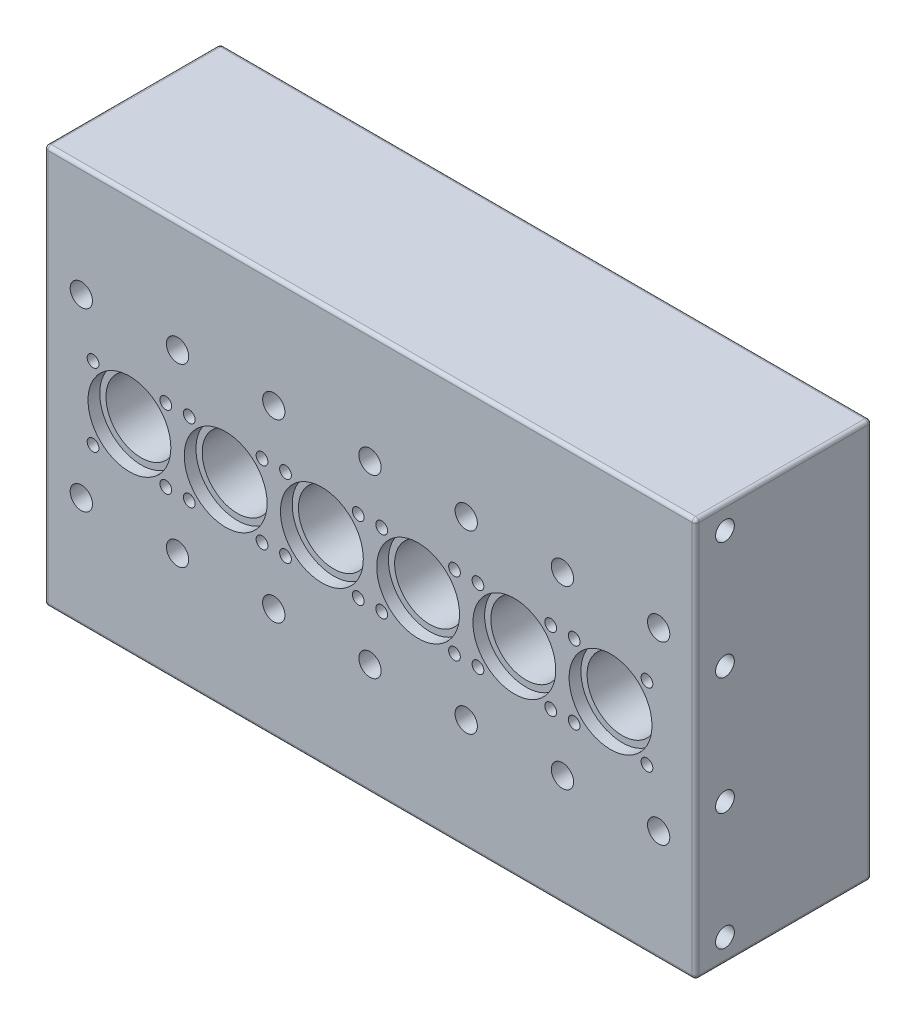
from build123d import *

# Parameters (mm, degrees)
SKETCH1_W                  = 555
SKETCH1_H                  = 340
BOSS_EXTRUDE1_DEPTH        = 75
SKETCH3_R                  = 35.3
CUT_EXTRUDE1_DEPTH         = 10
SKETCH5_R                  = 30
CUT_EXTRUDE2_DEPTH         = 110
SKETCH6_R                  = 27
CUT_EXTRUDE3_DEPTH         = 218
SKETCH7_W                  = 32
SKETCH7_H                  = 68
CUT_EXTRUDE4_DEPTH         = 30
SKETCH8_R                  = 5
CUT_EXTRUDE5_DEPTH         = 23
LPATTERN1_COUNT            = 2
LPATTERN1_PITCH            = 62
LPATTERN1_COUNT_DIR2       = 2
LPATTERN1_PITCH_DIR2       = 62
LPATTERN2_COUNT            = 6
LPATTERN2_PITCH            = 82
LPATTERN2_COPY_1_SKETCH_R  = 5
LPATTERN2_COPY_1_DEPTH     = 23
LPATTERN2_COPY_2_SKETCH_R  = 5
LPATTERN2_COPY_2_DEPTH     = 23
LPATTERN2_COPY_3_SKETCH_R  = 5
LPATTERN2_COPY_3_DEPTH     = 23
LPATTERN2_COPY_4_SKETCH_R  = 5
LPATTERN2_COPY_4_DEPTH     = 23
LPATTERN2_COPY_5_SKETCH_R  = 5
LPATTERN2_COPY_5_DEPTH     = 23
LPATTERN2_COPY_6_SKETCH_R  = 5
LPATTERN2_COPY_6_DEPTH     = 23
LPATTERN2_COPY_7_SKETCH_R  = 5
LPATTERN2_COPY_7_DEPTH     = 23
LPATTERN2_COPY_8_SKETCH_R  = 5
LPATTERN2_COPY_8_DEPTH     = 23
LPATTERN2_COPY_9_SKETCH_R  = 5
LPATTERN2_COPY_9_DEPTH     = 23
LPATTERN2_COPY_10_SKETCH_R = 5
LPATTERN2_COPY_10_DEPTH    = 23
LPATTERN2_COPY_11_SKETCH_R = 5
LPATTERN2_COPY_11_DEPTH    = 23
LPATTERN2_COPY_12_SKETCH_R = 5
LPATTERN2_COPY_12_DEPTH    = 23
LPATTERN2_COPY_13_SKETCH_R = 5
LPATTERN2_COPY_13_DEPTH    = 23
LPATTERN2_COPY_14_SKETCH_R = 5
LPATTERN2_COPY_14_DEPTH    = 23
LPATTERN2_COPY_15_SKETCH_R = 5
LPATTERN2_COPY_15_DEPTH    = 23
SKETCH9_R                  = 9.5
CUT_EXTRUDE6_DEPTH         = 151
LPATTERN3_COUNT            = 7
LPATTERN3_PITCH            = 82
LPATTERN3_COUNT_DIR2       = 2
LPATTERN3_PITCH_DIR2       = 150
SKETCH14_R                 = 8
CUT_EXTRUDE7_DEPTH         = 556
LPATTERN4_COUNT            = 4
LPATTERN4_PITCH            = 100
FILLET1_R                  = 3


with BuildPart() as part:
    # Sketch1 → Boss-Extrude1 (new body, symmetric)
    with BuildSketch(Plane.XY):
        with Locations((277.5, 170)):
            Rectangle(SKETCH1_W, SKETCH1_H)
    extrude(amount=BOSS_EXTRUDE1_DEPTH, both=True)

    # Sketch3 → Cut-Extrude1 (cut)
    with BuildSketch(Plane.XY.offset(75)):
        with Locations((72.5, 170)):
            Circle(SKETCH3_R)
    cut_extrude1 = extrude(amount=-CUT_EXTRUDE1_DEPTH, mode=Mode.SUBTRACT)

    # Sketch5 → Cut-Extrude2 (cut)
    with BuildSketch(Plane.XY.offset(65)):
        with Locations((72.5, 170)):
            Circle(SKETCH5_R)
    cut_extrude2 = extrude(amount=-CUT_EXTRUDE2_DEPTH, mode=Mode.SUBTRACT)

    # Sketch6 → Cut-Extrude3 (cut)
    with BuildSketch(Plane.XY.offset(-45)):
        with Locations((72.5, 170)):
            Circle(SKETCH6_R)
    cut_extrude3 = extrude(amount=-CUT_EXTRUDE3_DEPTH, mode=Mode.SUBTRACT)

    # Sketch7 → Cut-Extrude4 (cut)
    with BuildSketch(Plane(origin=(0, 0, -75), x_dir=(-1, 0, 0), z_dir=(0, 0, -1))):
        with Locations((-72.5, 170)):
            Rectangle(SKETCH7_W, SKETCH7_H)
    cut_extrude4 = extrude(amount=-CUT_EXTRUDE4_DEPTH, mode=Mode.SUBTRACT)

    # Sketch8 → Cut-Extrude5 (cut)
    with BuildSketch(Plane.XY.offset(75)):
        with Locations((41.5, 201)):
            Circle(SKETCH8_R)
    cut_extrude5 = extrude(amount=-CUT_EXTRUDE5_DEPTH, mode=Mode.SUBTRACT)

    # LPattern1: Cut-Extrude5 2 × 2
    with Locations(*[(i * LPATTERN1_PITCH, -j * LPATTERN1_PITCH_DIR2, 0) for i in range(LPATTERN1_COUNT) for j in range(LPATTERN1_COUNT_DIR2) if (i, j) != (0, 0)]):
        add(cut_extrude5, mode=Mode.SUBTRACT)

    # LPattern2: Cut-Extrude1, Cut-Extrude2, Cut-Extrude3, Cut-Extrude4, Cut-Extrude5 ×6
    with Locations(*[(i * LPATTERN2_PITCH, 0, 0) for i in range(1, LPATTERN2_COUNT)]):
        add(cut_extrude1, mode=Mode.SUBTRACT)
        add(cut_extrude2, mode=Mode.SUBTRACT)
        add(cut_extrude3, mode=Mode.SUBTRACT)
        add(cut_extrude4, mode=Mode.SUBTRACT)
        add(cut_extrude5, mode=Mode.SUBTRACT)

    # LPattern2 copy 1 sketch → LPattern2 copy 1 (cut)
    with BuildSketch(Plane(origin=(82, -62, 75), x_dir=(1, 0, 0), z_dir=(0, 0, 1))):
        with Locations((41.5, 201)):
            Circle(LPATTERN2_COPY_1_SKETCH_R)
    extrude(amount=-LPATTERN2_COPY_1_DEPTH, mode=Mode.SUBTRACT)

    # LPattern2 copy 2 sketch → LPattern2 copy 2 (cut)
    with BuildSketch(Plane(origin=(164, -62, 75), x_dir=(1, 0, 0), z_dir=(0, 0, 1))):
        with Locations((41.5, 201)):
            Circle(LPATTERN2_COPY_2_SKETCH_R)
    extrude(amount=-LPATTERN2_COPY_2_DEPTH, mode=Mode.SUBTRACT)

    # LPattern2 copy 3 sketch → LPattern2 copy 3 (cut)
    with BuildSketch(Plane(origin=(246, -62, 75), x_dir=(1, 0, 0), z_dir=(0, 0, 1))):
        with Locations((41.5, 201)):
            Circle(LPATTERN2_COPY_3_SKETCH_R)
    extrude(amount=-LPATTERN2_COPY_3_DEPTH, mode=Mode.SUBTRACT)

    # LPattern2 copy 4 sketch → LPattern2 copy 4 (cut)
    with BuildSketch(Plane(origin=(328, -62, 75), x_dir=(1, 0, 0), z_dir=(0, 0, 1))):
        with Locations((41.5, 201)):
            Circle(LPATTERN2_COPY_4_SKETCH_R)
    extrude(amount=-LPATTERN2_COPY_4_DEPTH, mode=Mode.SUBTRACT)

    # LPattern2 copy 5 sketch → LPattern2 copy 5 (cut)
    with BuildSketch(Plane(origin=(410, -62, 75), x_dir=(1, 0, 0), z_dir=(0, 0, 1))):
        with Locations((41.5, 201)):
            Circle(LPATTERN2_COPY_5_SKETCH_R)
    extrude(amount=-LPATTERN2_COPY_5_DEPTH, mode=Mode.SUBTRACT)

    # LPattern2 copy 6 sketch → LPattern2 copy 6 (cut)
    with BuildSketch(Plane(origin=(144, 0, 75), x_dir=(1, 0, 0), z_dir=(0, 0, 1))):
        with Locations((41.5, 201)):
            Circle(LPATTERN2_COPY_6_SKETCH_R)
    extrude(amount=-LPATTERN2_COPY_6_DEPTH, mode=Mode.SUBTRACT)

    # LPattern2 copy 7 sketch → LPattern2 copy 7 (cut)
    with BuildSketch(Plane(origin=(226, 0, 75), x_dir=(1, 0, 0), z_dir=(0, 0, 1))):
        with Locations((41.5, 201)):
            Circle(LPATTERN2_COPY_7_SKETCH_R)
    extrude(amount=-LPATTERN2_COPY_7_DEPTH, mode=Mode.SUBTRACT)

    # LPattern2 copy 8 sketch → LPattern2 copy 8 (cut)
    with BuildSketch(Plane(origin=(308, 0, 75), x_dir=(1, 0, 0), z_dir=(0, 0, 1))):
        with Locations((41.5, 201)):
            Circle(LPATTERN2_COPY_8_SKETCH_R)
    extrude(amount=-LPATTERN2_COPY_8_DEPTH, mode=Mode.SUBTRACT)

    # LPattern2 copy 9 sketch → LPattern2 copy 9 (cut)
    with BuildSketch(Plane(origin=(390, 0, 75), x_dir=(1, 0, 0), z_dir=(0, 0, 1))):
        with Locations((41.5, 201)):
            Circle(LPATTERN2_COPY_9_SKETCH_R)
    extrude(amount=-LPATTERN2_COPY_9_DEPTH, mode=Mode.SUBTRACT)

    # LPattern2 copy 10 sketch → LPattern2 copy 10 (cut)
    with BuildSketch(Plane(origin=(472, 0, 75), x_dir=(1, 0, 0), z_dir=(0, 0, 1))):
        with Locations((41.5, 201)):
            Circle(LPATTERN2_COPY_10_SKETCH_R)
    extrude(amount=-LPATTERN2_COPY_10_DEPTH, mode=Mode.SUBTRACT)

    # LPattern2 copy 11 sketch → LPattern2 copy 11 (cut)
    with BuildSketch(Plane(origin=(144, -62, 75), x_dir=(1, 0, 0), z_dir=(0, 0, 1))):
        with Locations((41.5, 201)):
            Circle(LPATTERN2_COPY_11_SKETCH_R)
    extrude(amount=-LPATTERN2_COPY_11_DEPTH, mode=Mode.SUBTRACT)

    # LPattern2 copy 12 sketch → LPattern2 copy 12 (cut)
    with BuildSketch(Plane(origin=(226, -62, 75), x_dir=(1, 0, 0), z_dir=(0, 0, 1))):
        with Locations((41.5, 201)):
            Circle(LPATTERN2_COPY_12_SKETCH_R)
    extrude(amount=-LPATTERN2_COPY_12_DEPTH, mode=Mode.SUBTRACT)

    # LPattern2 copy 13 sketch → LPattern2 copy 13 (cut)
    with BuildSketch(Plane(origin=(308, -62, 75), x_dir=(1, 0, 0), z_dir=(0, 0, 1))):
        with Locations((41.5, 201)):
            Circle(LPATTERN2_COPY_13_SKETCH_R)
    extrude(amount=-LPATTERN2_COPY_13_DEPTH, mode=Mode.SUBTRACT)

    # LPattern2 copy 14 sketch → LPattern2 copy 14 (cut)
    with BuildSketch(Plane(origin=(390, -62, 75), x_dir=(1, 0, 0), z_dir=(0, 0, 1))):
        with Locations((41.5, 201)):
            Circle(LPATTERN2_COPY_14_SKETCH_R)
    extrude(amount=-LPATTERN2_COPY_14_DEPTH, mode=Mode.SUBTRACT)

    # LPattern2 copy 15 sketch → LPattern2 copy 15 (cut)
    with BuildSketch(Plane(origin=(472, -62, 75), x_dir=(1, 0, 0), z_dir=(0, 0, 1))):
        with Locations((41.5, 201)):
            Circle(LPATTERN2_COPY_15_SKETCH_R)
    extrude(amount=-LPATTERN2_COPY_15_DEPTH, mode=Mode.SUBTRACT)

    # Sketch9 → Cut-Extrude6 (cut, through all)
    with BuildSketch(Plane.XY.offset(75)):
        with Locations((31.5, 245)):
            Circle(SKETCH9_R)
    cut_extrude6 = extrude(amount=-CUT_EXTRUDE6_DEPTH, mode=Mode.SUBTRACT)

    # LPattern3: Cut-Extrude6 7 × 2
    with Locations(*[(i * LPATTERN3_PITCH, -j * LPATTERN3_PITCH_DIR2, 0) for i in range(LPATTERN3_COUNT) for j in range(LPATTERN3_COUNT_DIR2) if (i, j) != (0, 0)]):
        add(cut_extrude6, mode=Mode.SUBTRACT)

    # Sketch14 → Cut-Extrude7 (cut, through all)
    with BuildSketch(Plane(origin=(555, 0, 0), x_dir=(0, 0, -1), z_dir=(1, 0, 0))):
        with Locations((-50, 20)):
            Circle(SKETCH14_R)
    cut_extrude7 = extrude(amount=-CUT_EXTRUDE7_DEPTH, mode=Mode.SUBTRACT)

    # LPattern4: Cut-Extrude7 ×4
    with Locations(*[(0, i * LPATTERN4_PITCH, 0) for i in range(1, LPATTERN4_COUNT)]):
        add(cut_extrude7, mode=Mode.SUBTRACT)

    # Fillet1
    fillet1_edges = [part.edges().sort_by_distance(p)[0] for p in [
        (555, 170, 75),
        (277.5, 340, 75),
        (0, 170, 75),
        (277.5, 340, -75),
        (555, 170, -75),
        (277.5, 0, -75),
        (0, 170, -75),
        (0, 340, 0),
        (555, 340, 0),
        (555, 0, 0),
        (0, 0, 0),
        (277.5, 0, 75),
    ]]
    fillet(fillet1_edges, radius=FILLET1_R)


solid = part.part
